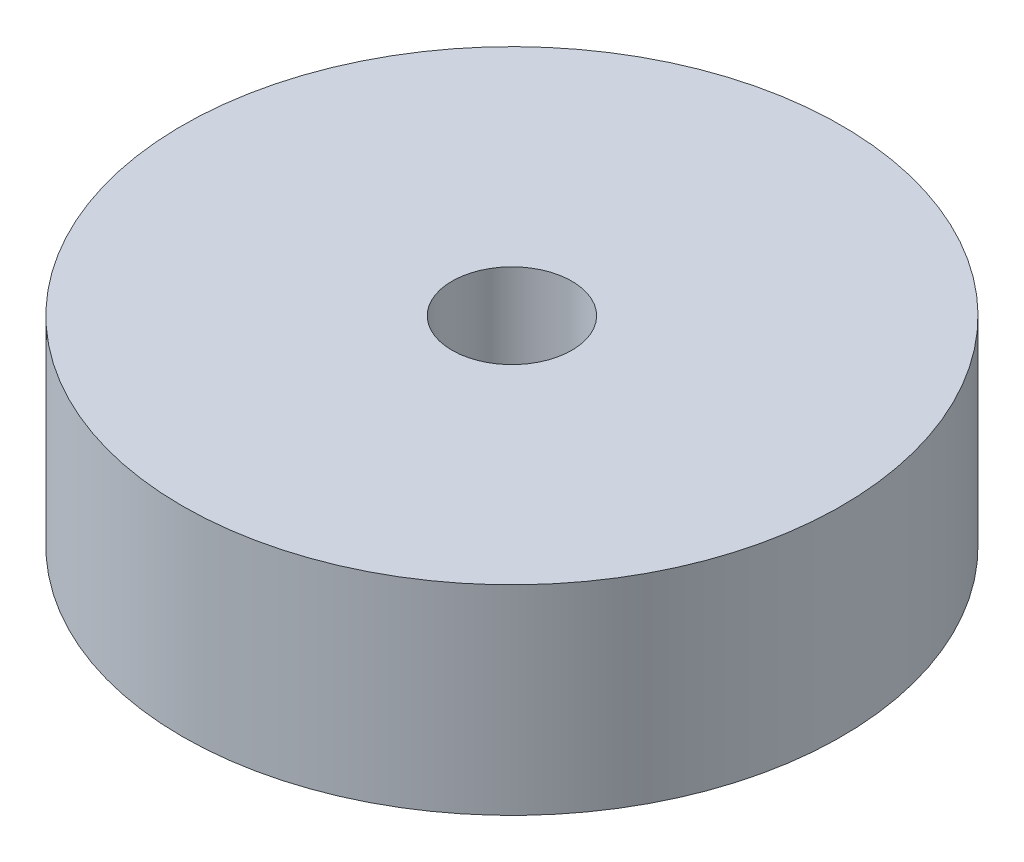
from build123d import *

# Parameters (mm, degrees)
SKETCH1_R           = 33
BOSS_EXTRUDE1_DEPTH = 20
SKETCH2_R           = 6
CUT_EXTRUDE1_DEPTH  = 20


with BuildPart() as part:
    # Sketch1 → Boss-Extrude1 (new body)
    with BuildSketch(Plane(origin=(0, 0, 0), x_dir=(1, 0, 0), z_dir=(0, 1, 0))):
        Circle(SKETCH1_R)
    extrude(amount=BOSS_EXTRUDE1_DEPTH)

    # Sketch2 → Cut-Extrude1 (cut)
    with BuildSketch(Plane(origin=(0, 20, 0), x_dir=(1, 0, 0), z_dir=(0, 1, 0))):
        Circle(SKETCH2_R)
    extrude(amount=-CUT_EXTRUDE1_DEPTH, mode=Mode.SUBTRACT)


solid = part.part
